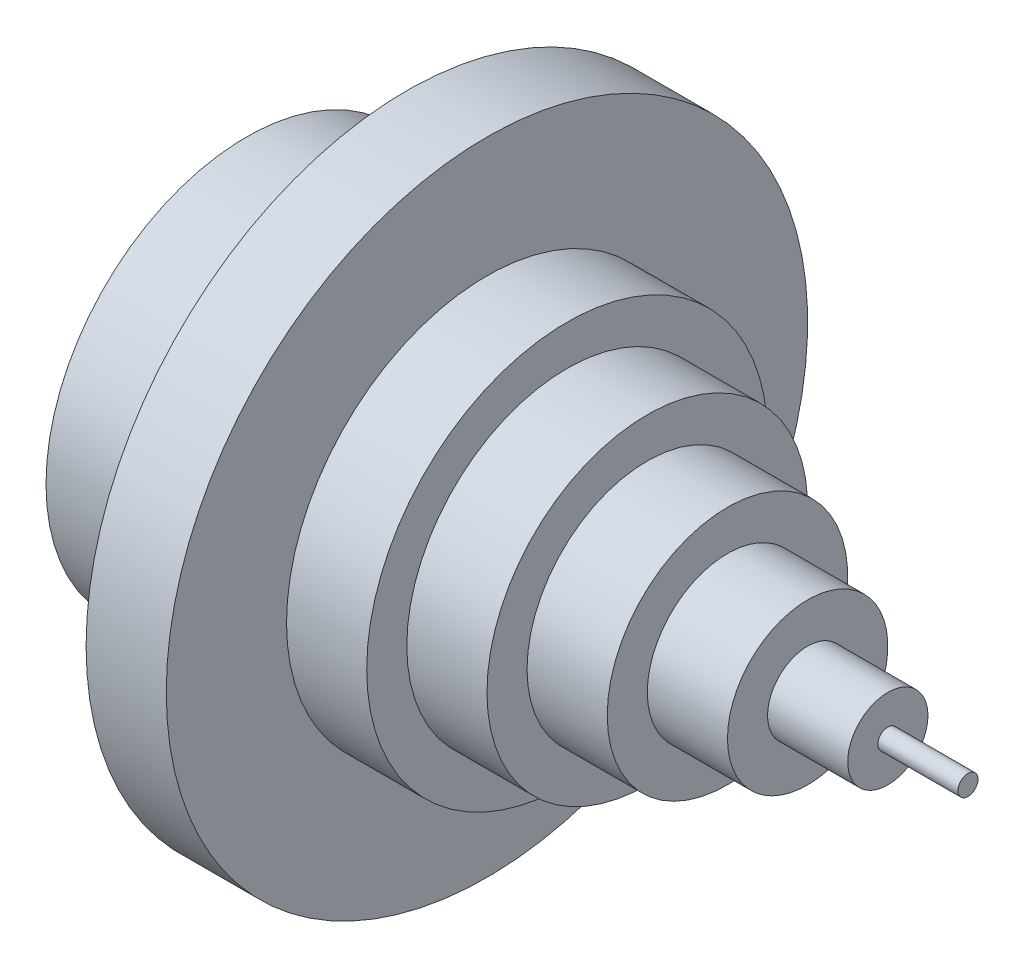
from build123d import *

# Parameters (mm, degrees)
SKETCH8_R          = 40
CUT_EXTRUDE3_DEPTH = 40


with BuildPart() as part:
    # Sketch2 → Revolve4 (revolve)
    with BuildSketch(Plane.XY, mode=Mode.PRIVATE) as revolve4_sk:
        Polygon((40, 50), (40, 80), (60, 80), (60, 50), (80, 50), (80, 40), (100, 40), (100, 30), (120, 30), (120, 20), (140, 20), (140, 10), (160, 10), (160, 2.5), (180, 2.5), (180, 0), (0, 0), (0, 50), align=None)
    revolve(revolve4_sk.sketch.rotate(Axis((-106.966820462, 0, 0), (1, 0, 0)), 90), axis=Axis((-106.966820462, 0, 0), (1, 0, 0)))  # turned: the seam where the file's is

    # Sketch8 → Cut-Extrude3 (cut)
    with BuildSketch(Plane.ZY):
        Circle(SKETCH8_R)
    extrude(amount=-CUT_EXTRUDE3_DEPTH, mode=Mode.SUBTRACT)


solid = part.part
